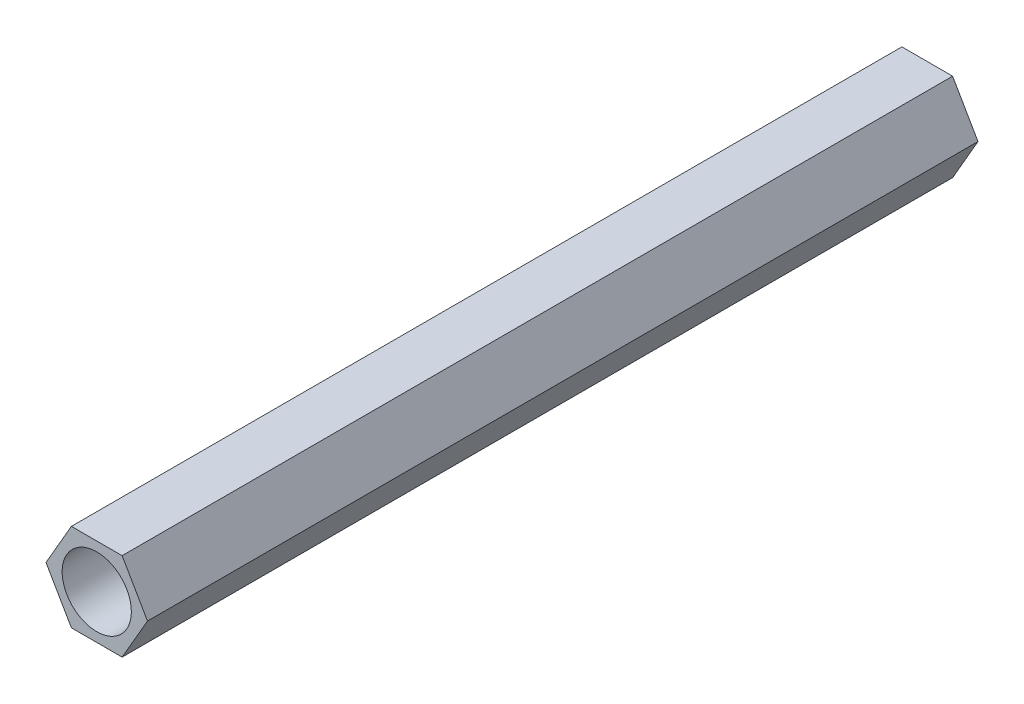
from build123d import *

# Parameters (mm, degrees)
SKETCH1_R           = 2.5
BOSS_EXTRUDE1_DEPTH = 60


with BuildPart() as part:
    # Sketch1 → Boss-Extrude1 (new body)
    with BuildSketch(Plane.XY):
        Polygon((3.666174209, 0), (1.833087105, 3.175), (-1.833087105, 3.175), (-3.666174209, 0), (-1.833087105, -3.175), (1.833087105, -3.175), align=None)
        Circle(SKETCH1_R, mode=Mode.SUBTRACT)
    extrude(amount=BOSS_EXTRUDE1_DEPTH)


solid = part.part
